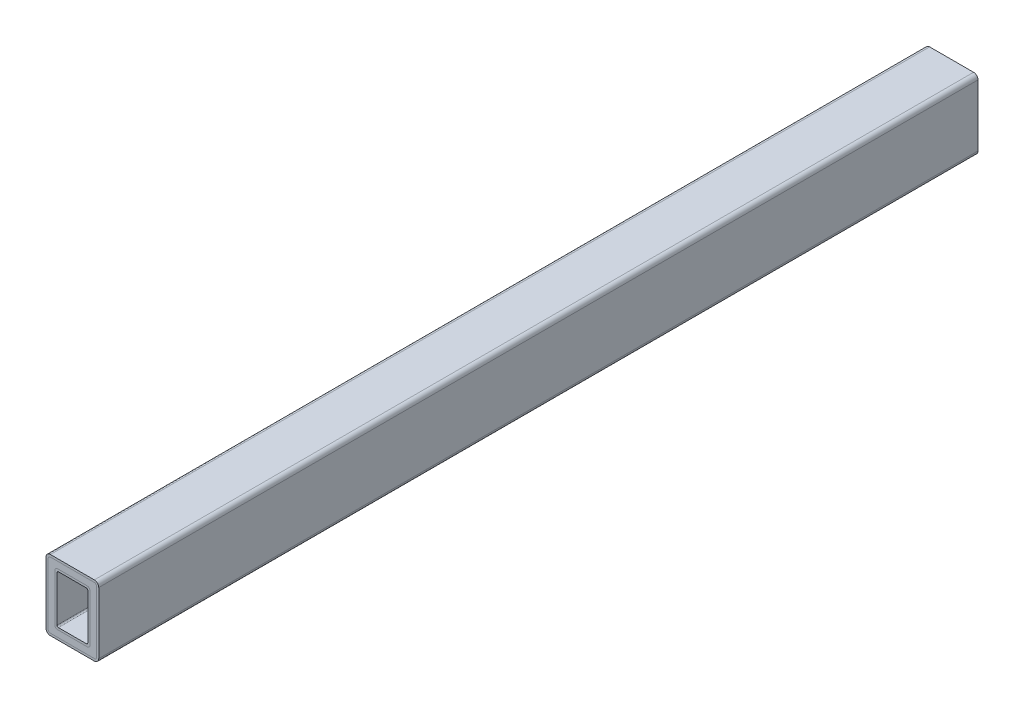
from build123d import *

# Parameters (mm, degrees)
BOSS_EXTRUDE1_DEPTH = 635
BOSS_EXTRUDE4_START = 635
SKETCH8_W           = 50.8
SKETCH8_H           = 76.2
SKETCH8_W_2         = 44.45
SKETCH8_H_2         = 69.85
BOSS_EXTRUDE4_DEPTH = 1270
FILLET1_R           = 4
FILLET2_R           = 2
BOSS_EXTRUDE5_DEPTH = 1270


with BuildPart() as part:
    # Sketch4 → Boss-Extrude1 (new body, symmetric)
    with BuildSketch(Plane.XY):
        with BuildLine():
            Line((31.75, -50.865662775), (-31.75, -50.865662775))
            ThreePointArc((-31.75, -50.865662775), (-36.240128061, -49.005790836), (-38.1, -44.515662775))
            Line((-38.1, -44.515662775), (-38.1, 44.384337225))
            ThreePointArc((-38.1, 44.384337225), (-36.240128061, 48.874465286), (-31.75, 50.734337225))
            Line((-31.75, 50.734337225), (31.75, 50.734337225))
            ThreePointArc((31.75, 50.734337225), (36.240128061, 48.874465286), (38.1, 44.384337225))
            Line((38.1, 44.384337225), (38.1, -44.515662775))
            ThreePointArc((38.1, -44.515662775), (36.240128061, -49.005790836), (31.75, -50.865662775))
        make_face()
        with BuildLine():
            Line((31.75, -47.690662775), (-31.75, -47.690662775))
            ThreePointArc((-31.75, -47.690662775), (-33.99506403, -46.760726805), (-34.925, -44.515662775))
            Line((-34.925, -44.515662775), (-34.925, 44.384337225))
            ThreePointArc((-34.925, 44.384337225), (-33.99506403, 46.629401255), (-31.75, 47.559337225))
            Line((-31.75, 47.559337225), (31.75, 47.559337225))
            ThreePointArc((31.75, 47.559337225), (33.99506403, 46.629401255), (34.925, 44.384337225))
            Line((34.925, 44.384337225), (34.925, -44.515662775))
            ThreePointArc((34.925, -44.515662775), (33.99506403, -46.760726805), (31.75, -47.690662775))
        make_face(mode=Mode.SUBTRACT)
    extrude(amount=BOSS_EXTRUDE1_DEPTH, both=True)


with BuildPart() as body_2:
    # Sketch8 → Boss-Extrude4 (new body)
    with BuildSketch(Plane.XY.offset(BOSS_EXTRUDE4_START)):
        Rectangle(SKETCH8_W, SKETCH8_H)
        Rectangle(SKETCH8_W_2, SKETCH8_H_2, mode=Mode.SUBTRACT)
    extrude(amount=-BOSS_EXTRUDE4_DEPTH)

    # Fillet1
    fillet1_edges = [body_2.edges().sort_by_distance(p)[0] for p in [
        (25.4, 38.1, 0),
        (25.4, -38.1, 0),
        (-25.4, -38.1, 0),
        (-25.4, 38.1, 0),
    ]]
    fillet(fillet1_edges, radius=FILLET1_R)

    # Fillet2
    fillet2_edges = [body_2.edges().sort_by_distance(p)[0] for p in [
        (22.225, -34.925, 0),
        (-22.225, -34.925, 0),
        (-22.225, 34.925, 0),
        (22.225, 34.925, 0),
    ]]
    fillet(fillet2_edges, radius=FILLET2_R)


with BuildPart() as body_3:
    # Sketch9 → Boss-Extrude5 (new body)
    with BuildSketch(Plane(origin=(0, 0, -635), x_dir=(-1, 0, 0), z_dir=(0, 0, -1))):
        with BuildLine():
            Line((31.75, -47.690662775), (-31.75, -47.690662775))
            ThreePointArc((-31.75, -47.690662775), (-33.99506403, -46.760726805), (-34.925, -44.515662775))
            Line((-34.925, -44.515662775), (-34.925, 44.384337225))
            ThreePointArc((-34.925, 44.384337225), (-33.99506403, 46.629401255), (-31.75, 47.559337225))
            Line((-31.75, 47.559337225), (31.75, 47.559337225))
            ThreePointArc((31.75, 47.559337225), (33.99506403, 46.629401255), (34.925, 44.384337225))
            Line((34.925, 44.384337225), (34.925, -44.515662775))
            ThreePointArc((34.925, -44.515662775), (33.99506403, -46.760726805), (31.75, -47.690662775))
        make_face()
        with BuildLine():
            Line((21.4, -38.1), (-21.4, -38.1))
            ThreePointArc((-21.4, -38.1), (-24.228427125, -36.928427125), (-25.4, -34.1))
            Line((-25.4, -34.1), (-25.4, 34.1))
            ThreePointArc((-25.4, 34.1), (-24.228427125, 36.928427125), (-21.4, 38.1))
            Line((-21.4, 38.1), (21.4, 38.1))
            ThreePointArc((21.4, 38.1), (24.228427125, 36.928427125), (25.4, 34.1))
            Line((25.4, 34.1), (25.4, -34.1))
            ThreePointArc((25.4, -34.1), (24.228427125, -36.928427125), (21.4, -38.1))
        make_face(mode=Mode.SUBTRACT)
    extrude(amount=-BOSS_EXTRUDE5_DEPTH)


solid = Compound([part.part, body_2.part, body_3.part])
